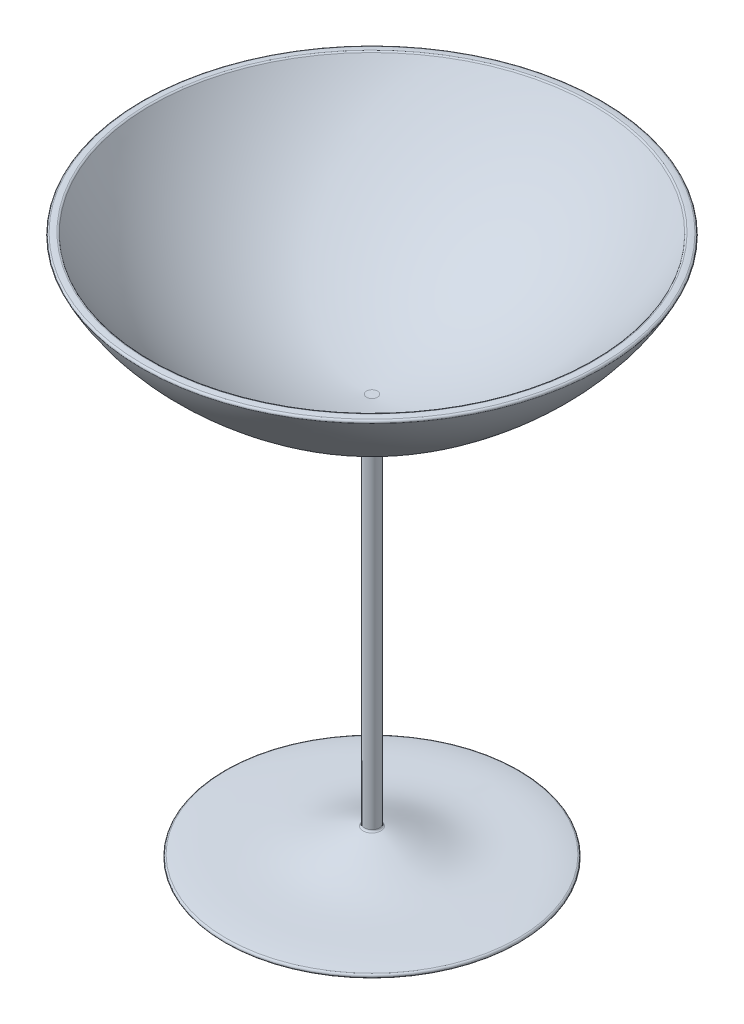
from build123d import *

# Parameters (mm, degrees)
FILLET1_R = 0.5
FILLET2_R = 0.5


with BuildPart() as part:
    # Sketch1 → Revolve2 (revolve)
    with BuildSketch(Plane.XY):
        with BuildLine():
            Line((-1.886642267, 0), (-1.886642267, -94.612786767))
            add(Edge.make_bspline(
                [(-1.886642267, -94.612786767), (-6.83160133, -95.891459777), (-19.07102765, -102.372099832), (-33.118499178, -99.28148197), (-40.946034813, -101.993707722)],
                knots=[0, 0, 0, 0, 0.386922085, 1, 1, 1, 1], degree=3))
            Line((-40.946034813, -101.993707722), (-18.976501423, -101.993707722))
            add(Edge.make_bspline(
                [(-18.976501423, -101.993707722), (-15.171385249, -101.884491553), (-8.886530255, -99.898195702), (-2.764831651, -97.500393926), (0, -96.991755192)],
                knots=[0, 0, 0, 0, 0.572892545, 1, 1, 1, 1], degree=3))
            Line((0, -96.991755192), (0, 0.457810217))
            add(Edge.make_bspline(
                [(-1.386642151, 0.457810217), (-0.925353782, 0.419752043), (-0.461493172, 0.43057108), (0, 0.457810217)],
                knots=[0, 0, 0, 0, 1, 1, 1, 1], degree=3))
            add(Edge.make_bspline(
                [(-1.386642151, 0.457810217), (-1.499441508, 0.467766744), (-1.692433227, 0.484872477), (-3.114470681, 0.609588512), (-5.841541743, 0.938384795), (-11.228118205, 1.964314794), (-18.007160307, 3.979793044), (-25.759924872, 7.417712415), (-35.508571936, 13.214167833), (-44.236533858, 20.616976444), (-51.688372429, 29.21472079), (-54.930903774, 33.818571485), (-56.434457232, 36.201201451)],
                knots=[-0.006651905, -0.006651905, -0.006651905, -0.006651905, -0.001662976, 0.001662976, 0.056263839, 0.119179583, 0.245011071, 0.370842559, 0.496674048, 0.748337024, 0.874168512, 1, 1, 1, 1], degree=3))
            add(Edge.make_bspline(
                [(-58.809972451, 35.934365424), (-58.429070629, 35.998115507), (-57.64282016, 36.129901354), (-56.847189048, 36.221547457), (-56.434457232, 36.201201451)],
                knots=[0, 0, 0, 0, 0.483682427, 1, 1, 1, 1], degree=3))
            add(Edge.make_bspline(
                [(-1.886642267, 0), (-9.703974981, 0.45881391), (-23.850286096, 4.006704857), (-43.408922852, 16.716010054), (-54.843748215, 27.82165464), (-58.809972451, 35.934365424)],
                knots=[0, 0, 0, 0, 0.337374472, 0.612444777, 1, 1, 1, 1], degree=3))
        make_face()
    revolve(axis=Axis((0, 0, 0), (0, 1, 0)))

    # Fillet1
    fillet1_edges = [part.edges().sort_by_distance(p)[0] for p in [
        (58.809972451, 35.934365424, 0),
        (56.434457232, 36.201201451, 0),
    ]]
    fillet(fillet1_edges, radius=FILLET1_R)

    # Fillet2
    fillet2_edges = [part.edges().sort_by_distance(p)[0] for p in [
        (40.946034813, -101.993707722, 0),
        (1.886642267, -94.612786767, 0),
        (1.886642267, 0, 0),
    ]]
    fillet(fillet2_edges, radius=FILLET2_R)


solid = part.part
